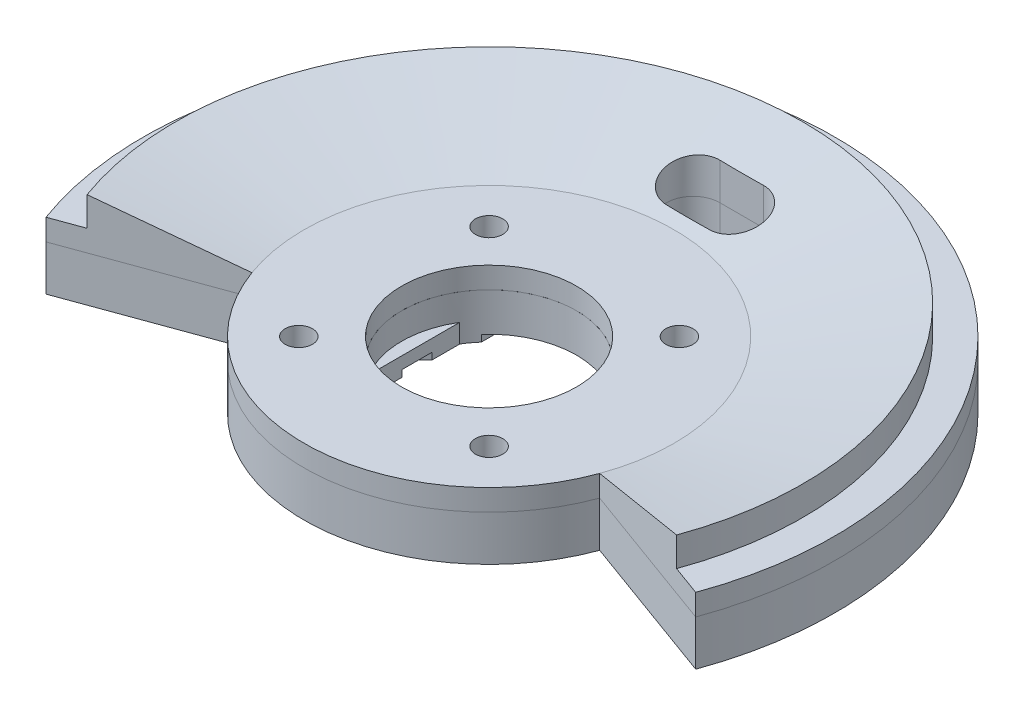
from build123d import *

# Parameters (mm, degrees)
BOSS_EXTRUDE1_START = -14.125
SKETCH2_R           = 27.5
SKETCH2_R_2         = 13.000000035
SKETCH2_R_3         = 2.025
BOSS_EXTRUDE1_DEPTH = 3.175
BOSS_EXTRUDE2_START = 28.4275
SKETCH3_R           = 18.35
SKETCH3_R_2         = 12
BOSS_EXTRUDE2_DEPTH = 6
REVOLVE1_ANGLE      = 220
SKETCH5_R           = 18.35
SKETCH5_R_2         = 11.20625
BOSS_EXTRUDE3_DEPTH = 0.79375
CUT_EXTRUDE1_REACH  = 91.201
CUT_EXTRUDE2_DEPTH  = 48.55249997
SKETCH8_R           = 2.025
SKETCH8_R_2         = 13.000000035
BOSS_EXTRUDE4_DEPTH = 6.723750032
SKETCH10_W          = 1.887500035
SKETCH10_H          = 13.492567534
BOSS_EXTRUDE5_DEPTH = 2.793750032
CUT_EXTRUDE3_DEPTH  = 1.000000032


with BuildPart() as part:
    # Sketch2 → Boss-Extrude1 (new body)
    with BuildSketch(Plane(origin=(0, 0, 0), x_dir=(1, 0, 0), z_dir=(0, 1, 0)).offset(BOSS_EXTRUDE1_START)):
        with Locations(Location((0, 0, 0), (0, 0, 270))):
            Circle(SKETCH2_R)
        with Locations(Location((0, 0, 0), (0, 0, 270))):
            Circle(SKETCH2_R_2, mode=Mode.SUBTRACT)
        with Locations(Location((-14.142135624, -14.142135624, 0), (0, 0, 270))):
            Circle(SKETCH2_R_3, mode=Mode.SUBTRACT)
        with Locations(Location((14.142135624, -14.142135624, 0), (0, 0, 270))):
            Circle(SKETCH2_R_3, mode=Mode.SUBTRACT)
        with Locations(Location((14.142135624, 14.142135624, 0), (0, 0, 270))):
            Circle(SKETCH2_R_3, mode=Mode.SUBTRACT)
        with Locations(Location((-14.142135624, 14.142135624, 0), (0, 0, 270))):
            Circle(SKETCH2_R_3, mode=Mode.SUBTRACT)
    extrude(amount=-BOSS_EXTRUDE1_DEPTH)



with BuildPart() as body_2:
    # Sketch3 → Boss-Extrude2 (new body)
    with BuildSketch(Plane(origin=(0, 0, 0), x_dir=(1, 0, 0), z_dir=(0, 1, 0)).offset(BOSS_EXTRUDE2_START)):
        with Locations(Location((0, 0, 0), (0, 0, 270))):
            Circle(SKETCH3_R)
        with Locations(Location((0, 0, 0), (0, 0, 270))):
            Circle(SKETCH3_R_2, mode=Mode.SUBTRACT)
    extrude(amount=BOSS_EXTRUDE2_DEPTH)


with BuildPart() as part_1:
    add(part.part)

    add(body_2.part)  # Revolve1 merges body 2
    # Sketch4 → Revolve1 (revolve, symmetric)
    with BuildSketch(Plane(origin=(0, 0, 0), x_dir=(0, 0, -1), z_dir=(1, 0, 0))) as revolve1_sk:
        Polygon((27.5, -17.3), (51.38625, -17.3), (51.38625, 34.42749997), (18.35, 34.42749997), (18.35, 28.427500017), (46.62375, 28.427500017), (46.62375, -9.795291189), (27.5, -14.125), align=None)
    revolve(axis=Axis((0, -14.125, 0), (0, 1, 0)), revolution_arc=REVOLVE1_ANGLE / 2)
    revolve(revolve1_sk.sketch, axis=Axis((0, -14.125, 0), (0, -1, 0)), revolution_arc=REVOLVE1_ANGLE / 2)

    # Sketch5 → Boss-Extrude3 (add)
    with BuildSketch(Plane.XZ.offset(-28.427500017)):
        with Locations(Location((0, 0, 0), (0, 0, 270))):
            Circle(SKETCH5_R)
        with Locations(Location((0, 0, 0), (0, 0, 270))):
            Circle(SKETCH5_R_2, mode=Mode.SUBTRACT)
    extrude(amount=BOSS_EXTRUDE3_DEPTH)

    # Cut-Extrude1: up to this cone (the profile starts outside it)
    cut_extrude1_end = Plane(origin=(0, -17.3, 0), z_dir=(0, 1, 0)).offset(-3.051131024) * Cone(4.417e-06, 478.031284628, 108.228576807, align=(Align.CENTER, Align.CENTER, Align.MIN), mode=Mode.PRIVATE)
    # Sketch6 → Cut-Extrude1 (cut, up to the surface)
    with BuildSketch(Plane(origin=(0, -17.3, 0), x_dir=(-1, 0, 0), z_dir=(0, -1, 0)), mode=Mode.PRIVATE) as cut_extrude1_sk1:
        with BuildLine():
            Line((3.25, 29.61125), (-3.25, 29.61125))
            ThreePointArc((-3.25, 29.61125), (-7.21875, 33.58), (-3.25, 37.54875))
            Line((-3.25, 37.54875), (3.25, 37.54875))
            ThreePointArc((3.25, 37.54875), (7.21875, 33.58), (3.25, 29.61125))
        make_face()
    cut_extrude1_tool1 = extrude(cut_extrude1_sk1.sketch, amount=-CUT_EXTRUDE1_REACH, mode=Mode.PRIVATE) - cut_extrude1_end
    add(cut_extrude1_tool1.solids().sort_by_distance((0, -17.3, -33.58))[0], mode=Mode.SUBTRACT)

    # Sketch7 → Cut-Extrude2 (cut)
    with BuildSketch(Plane(origin=(0, 34.42749997, 0), x_dir=(1, 0, 0), z_dir=(0, 1, 0))):
        with BuildLine():
            Line((-48.287279935, -17.57513259), (-43.811993828, -15.946261657))
            ThreePointArc((-43.811993828, -15.946261657), (0, 46.62375), (43.811993828, -15.946261657))
            Line((43.811993828, -15.946261657), (48.287279935, -17.57513259))
            ThreePointArc((48.287279935, -17.57513259), (0, 51.38625), (-48.287279935, -17.57513259))
        make_face()
    extrude(amount=-CUT_EXTRUDE2_DEPTH, mode=Mode.SUBTRACT)


with BuildPart() as cut_extrude2_kept_piece:
    # of the separate pieces the step leaves, the one the design keeps (cut_extrude2_pieces_kept)
    add(part_1.part.solids().sort_by_distance((-25.841547072, -14.125, 9.405553941))[0])


with BuildPart() as body_2_2:
    # Sketch8 → Boss-Extrude4 (new body)
    with BuildSketch(Plane.XZ.offset(17.3)):
        with BuildLine():
            Line((-25.841547072, 9.405553941), (-48.287279935, 17.57513259))
            ThreePointArc((-48.287279935, 17.57513259), (0, -51.38625), (48.287279935, 17.57513259))
            Line((48.287279935, 17.57513259), (25.841547072, 9.405553941))
            ThreePointArc((25.841547072, 9.405553941), (0, 27.5), (-25.841547072, 9.405553941))
        make_face()
        with Locations(Location((-14.142135624, -14.142135624, 0), (0, 0, 270))):
            Circle(SKETCH8_R, mode=Mode.SUBTRACT)
        with Locations(Location((14.142135624, -14.142135624, 0), (0, 0, 270))):
            Circle(SKETCH8_R, mode=Mode.SUBTRACT)
        with Locations(Location((14.142135624, 14.142135624, 0), (0, 0, 270))):
            Circle(SKETCH8_R, mode=Mode.SUBTRACT)
        with Locations(Location((-14.142135624, 14.142135624, 0), (0, 0, 270))):
            Circle(SKETCH8_R, mode=Mode.SUBTRACT)
        with Locations(Location((0, 0, 0), (0, 0, 270))):
            Circle(SKETCH8_R_2, mode=Mode.SUBTRACT)
        with BuildLine():
            Line((-3.25, -37.54875), (3.25, -37.54875))
            ThreePointArc((3.25, -37.54875), (7.21875, -33.58), (3.25, -29.61125))
            Line((3.25, -29.61125), (-3.25, -29.61125))
            ThreePointArc((-3.25, -29.61125), (-7.21875, -33.58), (-3.25, -37.54875))
        make_face(mode=Mode.SUBTRACT)
    extrude(amount=BOSS_EXTRUDE4_DEPTH)

    # Sketch10 → Boss-Extrude5 (add)
    with BuildSketch(Plane.XZ.offset(24.023750032)):
        with Locations((-12.056250018, 0)):
            Rectangle(SKETCH10_W, SKETCH10_H)
        with Locations((12.056250018, 0)):
            Rectangle(SKETCH10_W, SKETCH10_H)
    extrude(amount=-BOSS_EXTRUDE5_DEPTH)

    # Sketch12 → Cut-Extrude3 (cut)
    with BuildSketch(Plane.XZ.offset(24.023750032)):
        Polygon((-9.75400005, -3.981786238), (-9.75400005, -20.630576141), (9.75400005, -20.630576141), (9.75400005, -3.981786238), (12.754000146, -0.981786142), (12.754000146, 0.228634125), (9.75400005, 3.228634221), (9.75400005, 4.877423897), (-9.75400005, 4.877423897), (-9.75400005, 3.228634221), (-12.754000146, 0.228634125), (-12.754000146, -0.981786142), align=None)
    extrude(amount=-CUT_EXTRUDE3_DEPTH, mode=Mode.SUBTRACT)


solid = Compound([cut_extrude2_kept_piece.part, body_2_2.part])
